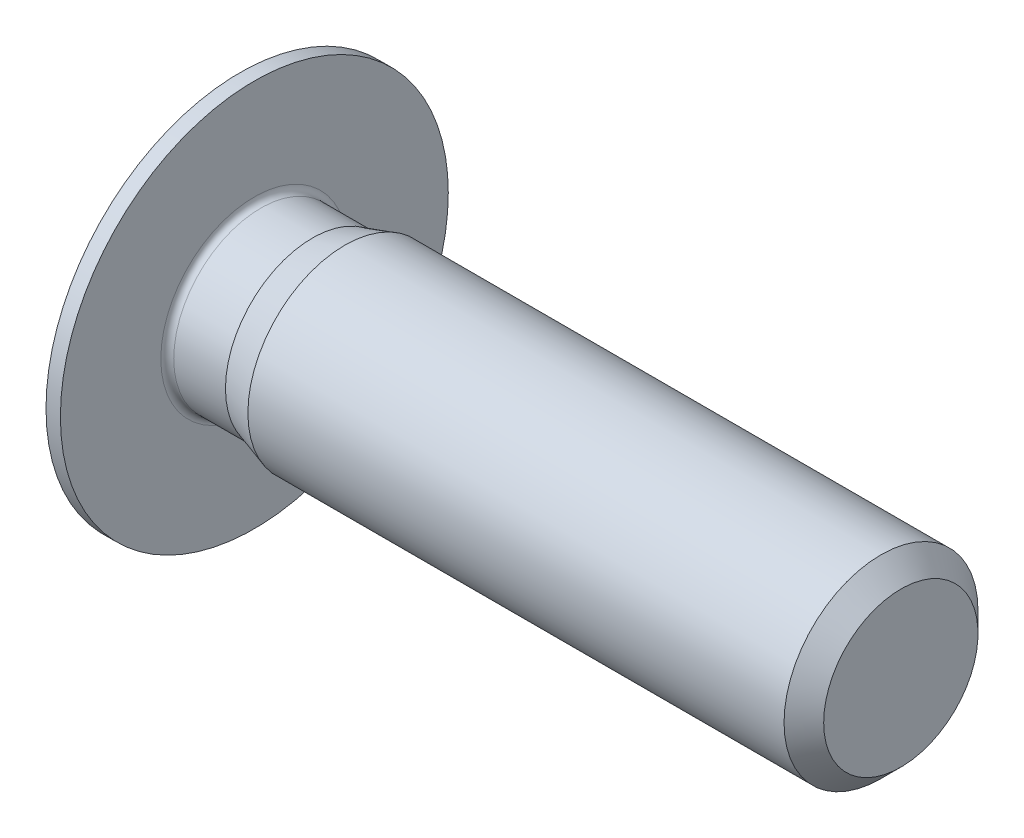
from build123d import *

# Parameters (mm, degrees)
CUT_EXTRUDE1_DEPTH = 2


with BuildPart() as part:
    # Sketch1 → Revolve1 (revolve)
    with BuildSketch(Plane.XY):
        with BuildLine():
            Line((-0.8, 0), (-0.8, 2))
            Line((-0.8, 2), (-0.222649731, 3))
            Line((-0.222649731, 3), (0, 3))
            Line((0, 3), (0, 1.44675))
            ThreePointArc((0, 1.44675), (0.029289322, 1.376039322), (0.1, 1.34675))
            Line((0.1, 1.34675), (0.9, 1.34675))
            Line((0.9, 1.34675), (1.4, 1.5))
            Line((1.4, 1.5), (9.6935, 1.5))
            Line((9.6935, 1.5), (10, 1.1935))
            Line((10, 1.1935), (10, 0))
            Line((10, 0), (-0.8, 0))
        make_face()
    revolve(axis=Axis((10, 0, 0), (-1, 0, 0)))

    # Sketch2 → Cut-Revolve1 (revolve, cut)
    with BuildSketch(Plane.XY):
        Polygon((-0.8, 0), (-0.8, 0.75), (1.2, 0.75), (1.633012702, 0), align=None)
    revolve(axis=Axis((1.633012702, 0, 0), (-1, 0, 0)), mode=Mode.SUBTRACT)

    # Sketch3 → Cut-Extrude1 (cut)
    with BuildSketch(Plane(origin=(-0.8, 0, 0), x_dir=(0, 0, -1), z_dir=(1, 0, 0))):
        Polygon((-0.75, -0.433012702), (0, -0.866025404), (0.75, -0.433012702), (0.75, 0.433012702), (0, 0.866025404), (-0.75, 0.433012702), align=None)
    extrude(amount=CUT_EXTRUDE1_DEPTH, mode=Mode.SUBTRACT)


solid = part.part
